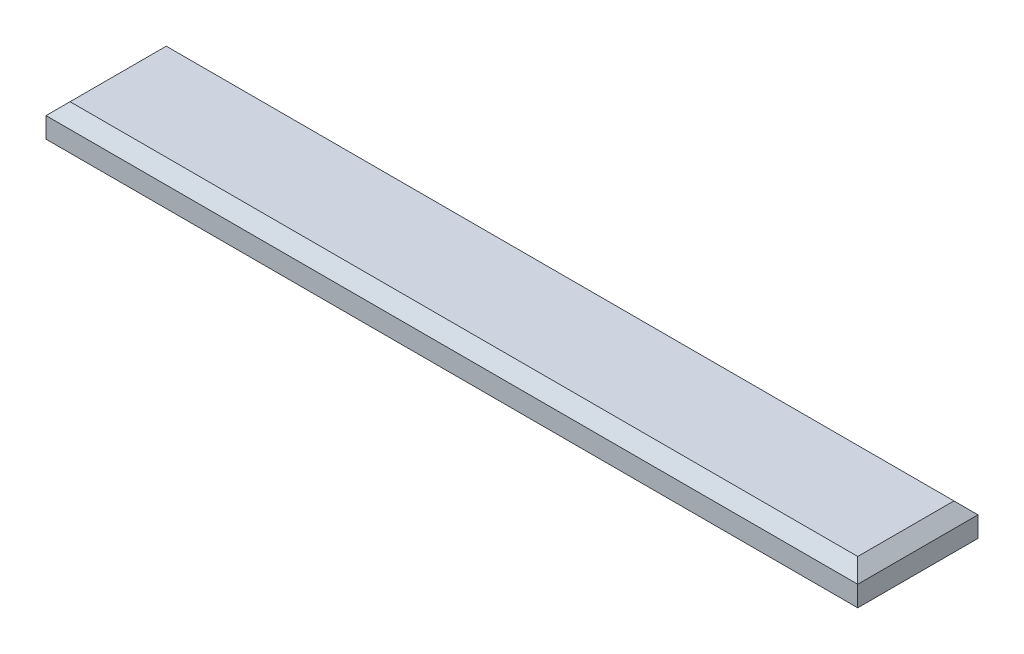
from build123d import *

# Parameters (mm, degrees)
SKETCH1_W           = 135
SKETCH1_H           = 20
BOSS_EXTRUDE1_DEPTH = 5.4
CHAMFER1_SIZE       = 2


with BuildPart() as part:
    # Sketch1 → Boss-Extrude1 (new body)
    with BuildSketch(Plane(origin=(0, 0, 0), x_dir=(1, 0, 0), z_dir=(0, 1, 0))):
        Rectangle(SKETCH1_W, SKETCH1_H)
    extrude(amount=BOSS_EXTRUDE1_DEPTH)

    # Chamfer1
    chamfer1_edges = [part.edges().sort_by_distance(p)[0] for p in [
        (-67.5, 5.4, 0),
        (0, 5.4, 10),
        (67.5, 5.4, 0),
        (0, 5.4, -10),
    ]]
    chamfer(chamfer1_edges, length=CHAMFER1_SIZE)


solid = part.part
